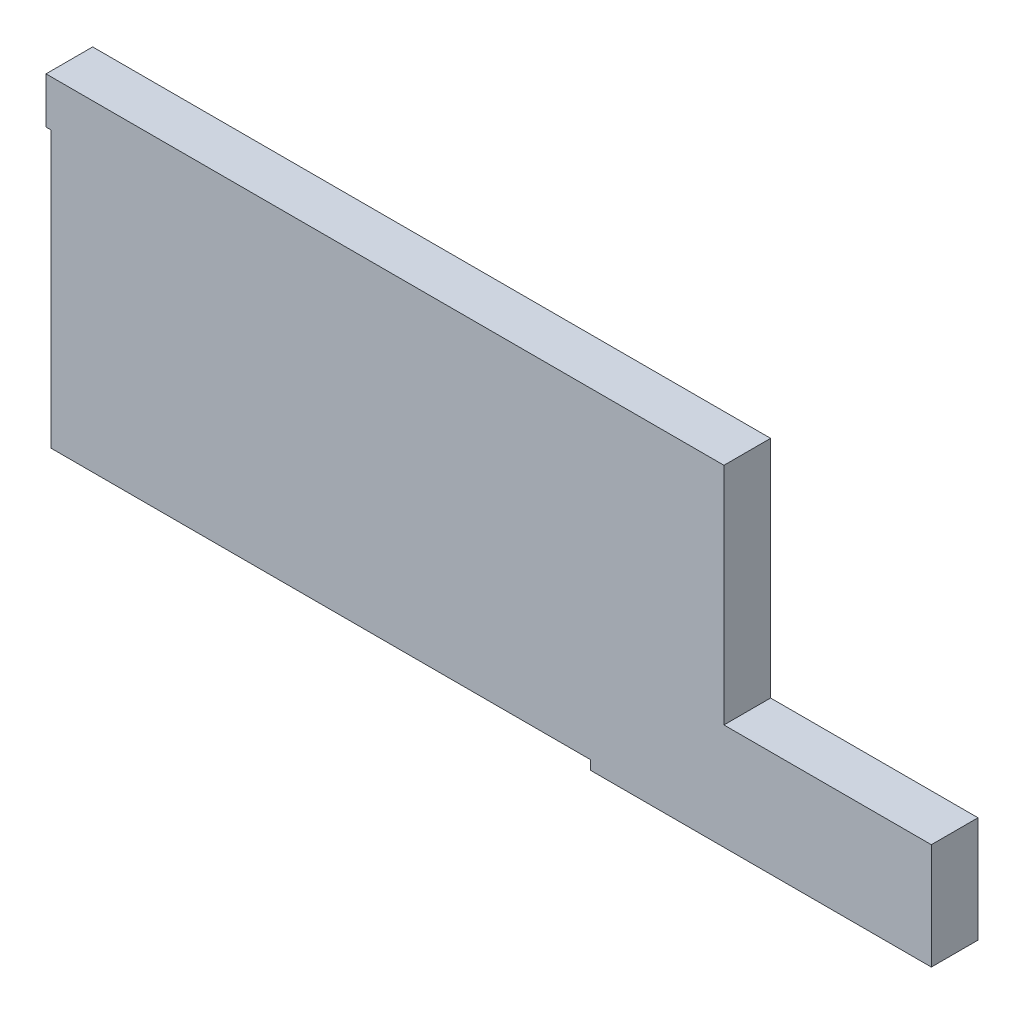
from build123d import *

# Parameters (mm, degrees)
BOSS_EXTRUDE1_DEPTH = 10.125


with BuildPart() as part:
    # Sketch2 → Boss-Extrude1 (new body)
    with BuildSketch(Plane.XY):
        Polygon((191, -14.196), (191, -37.196), (117, -37.196), (117, -35.196), (0, -35.196), (0, 24.604), (-1.1, 24.604), (-1.1, 34.604), (146, 34.604), (146, -14.196), align=None)
    extrude(amount=-BOSS_EXTRUDE1_DEPTH)


solid = part.part
